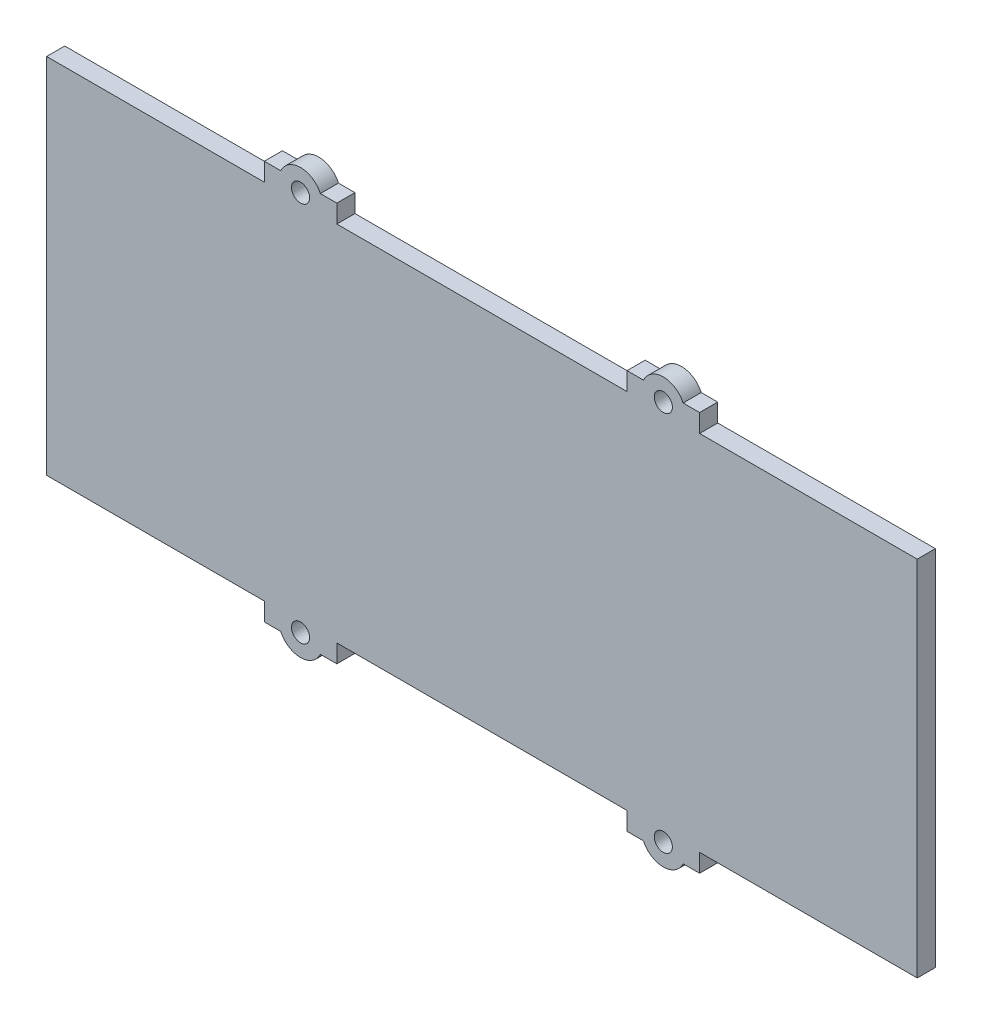
from build123d import *

# Parameters (mm, degrees)
SKETCH1_W                                    = 240
SKETCH1_H                                    = 100
BOSS_EXTRUDE1_DEPTH                          = 5
SKETCH2_W                                    = 20
SKETCH2_H                                    = 5
BOSS_EXTRUDE2_DEPTH                          = 5
MIRROR1_AT_THE_SECOND_PLANE_COPY_1_SKETC_W   = 20
MIRROR1_AT_THE_SECOND_PLANE_COPY_1_SKETC_H   = 5
MIRROR1_AT_THE_SECOND_PLANE_COPY_1_DEPTH     = 5
SKETCH3_R                                    = 6
SKETCH3_R_2                                  = 2
BOSS_EXTRUDE3_DEPTH                          = 5
SKETCH4_R                                    = 2.5
CUT_EXTRUDE2_DEPTH                           = 5
MIRROR2_AT_THE_SECOND_PLANE_COPY_1_SKETC_R   = 6
MIRROR2_AT_THE_SECOND_PLANE_COPY_1_SKETC_R_2 = 2
MIRROR2_AT_THE_SECOND_PLANE_COPY_1_DEPTH     = 5
MIRROR2_AT_THE_SECOND_PLANE_COPY_2_SKETC_R   = 2.5
MIRROR2_AT_THE_SECOND_PLANE_COPY_2_DEPTH     = 5


with BuildPart() as part:
    # Sketch1 → Boss-Extrude1 (new body)
    with BuildSketch(Plane.XY):
        Rectangle(SKETCH1_W, SKETCH1_H)
    extrude(amount=BOSS_EXTRUDE1_DEPTH)

    # Sketch2 → Boss-Extrude2 (add)
    with BuildSketch(Plane(origin=(0, 50, 0), x_dir=(1, 0, 0), z_dir=(0, 1, 0))):
        with Locations((50, -2.5)):
            Rectangle(SKETCH2_W, SKETCH2_H)
    boss_extrude2 = extrude(amount=BOSS_EXTRUDE2_DEPTH)

    # Mirror1: Boss-Extrude2 across plane
    add(boss_extrude2.mirror(Plane(origin=(0, 0, 0), x_dir=(0, 0, 1), z_dir=(1, 0, 0))))

    # Mirror1 at the second plane: Boss-Extrude2 across plane
    add(boss_extrude2.mirror(Plane.ZX))

    # Mirror1 at the second plane copy 1 sketc → Mirror1 at the second plane copy 1 (add)
    with BuildSketch(Plane(origin=(0, -50, 0), x_dir=(-1, 0, 0), z_dir=(0, -1, 0))):
        with Locations((50, -2.5)):
            Rectangle(MIRROR1_AT_THE_SECOND_PLANE_COPY_1_SKETC_W, MIRROR1_AT_THE_SECOND_PLANE_COPY_1_SKETC_H)
    extrude(amount=MIRROR1_AT_THE_SECOND_PLANE_COPY_1_DEPTH)

    # Sketch3 → Boss-Extrude3 (add)
    with BuildSketch(Plane.XY.offset(5)):
        with Locations((50, 52.5)):
            Circle(SKETCH3_R)
        with Locations((50, 52.5)):
            Circle(SKETCH3_R_2, mode=Mode.SUBTRACT)
    boss_extrude3 = extrude(amount=-BOSS_EXTRUDE3_DEPTH)

    # Sketch4 → Cut-Extrude2 (cut)
    with BuildSketch(Plane.XY.offset(5)):
        with Locations((50, 52.5)):
            Circle(SKETCH4_R)
    cut_extrude2 = extrude(amount=-CUT_EXTRUDE2_DEPTH, mode=Mode.SUBTRACT)

    # Mirror2: Boss-Extrude3, Cut-Extrude2 across plane
    add(boss_extrude3.mirror(Plane.ZX))
    add(cut_extrude2.mirror(Plane.ZX), mode=Mode.SUBTRACT)

    # Mirror2 at the second plane: Boss-Extrude3, Cut-Extrude2 across plane
    add(boss_extrude3.mirror(Plane(origin=(0, 0, 0), x_dir=(0, 0, 1), z_dir=(1, 0, 0))))
    add(cut_extrude2.mirror(Plane(origin=(0, 0, 0), x_dir=(0, 0, 1), z_dir=(1, 0, 0))), mode=Mode.SUBTRACT)

    # Mirror2 at the second plane copy 1 sketc → Mirror2 at the second plane copy 1 (add)
    with BuildSketch(Plane(origin=(0, 0, 5), x_dir=(-1, 0, 0), z_dir=(0, 0, 1))):
        with Locations((50, 52.5)):
            Circle(MIRROR2_AT_THE_SECOND_PLANE_COPY_1_SKETC_R)
        with Locations((50, 52.5)):
            Circle(MIRROR2_AT_THE_SECOND_PLANE_COPY_1_SKETC_R_2, mode=Mode.SUBTRACT)
    extrude(amount=-MIRROR2_AT_THE_SECOND_PLANE_COPY_1_DEPTH)

    # Mirror2 at the second plane copy 2 sketc → Mirror2 at the second plane copy 2 (cut)
    with BuildSketch(Plane(origin=(0, 0, 5), x_dir=(-1, 0, 0), z_dir=(0, 0, 1))):
        with Locations((50, 52.5)):
            Circle(MIRROR2_AT_THE_SECOND_PLANE_COPY_2_SKETC_R)
    extrude(amount=-MIRROR2_AT_THE_SECOND_PLANE_COPY_2_DEPTH, mode=Mode.SUBTRACT)


solid = part.part
